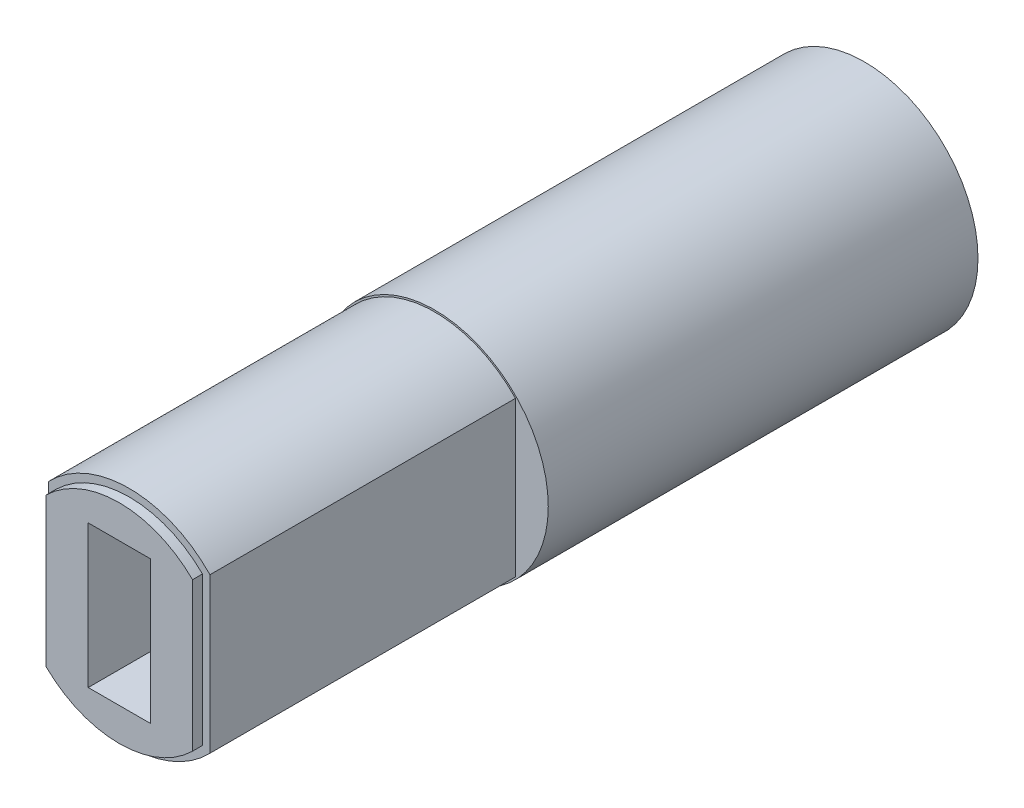
from build123d import *

# Parameters (mm, degrees)
SKETCH2_R           = 4.57
BOSS_EXTRUDE1_DEPTH = 17.3
BOSS_EXTRUDE3_DEPTH = 12.7
SKETCH5_W           = 2.5
SKETCH5_H           = 5.74
CUT_EXTRUDE1_DEPTH  = 31
SKETCH6_R           = 4.5
CUT_EXTRUDE3_DEPTH  = 0.4


with BuildPart() as part:
    # Sketch2 → Boss-Extrude1 (new body)
    with BuildSketch(Plane.XY):
        Circle(SKETCH2_R)
    extrude(amount=BOSS_EXTRUDE1_DEPTH)

    # Sketch4 → Boss-Extrude3 (add)
    with BuildSketch(Plane.XY.offset(17.3)):
        with BuildLine():
            Line((-3.25, 3.112474899), (-3.25, -3.112474899))
            ThreePointArc((-3.25, -3.112474899), (0, -4.5), (3.25, -3.112474899))
            Line((3.25, -3.112474899), (3.25, 3.112474899))
            ThreePointArc((3.25, 3.112474899), (0, 4.5), (-3.25, 3.112474899))
        make_face()
    extrude(amount=BOSS_EXTRUDE3_DEPTH)

    # Sketch5 → Cut-Extrude1 (cut, through all)
    with BuildSketch(Plane.XY.offset(30)):
        Rectangle(SKETCH5_W, SKETCH5_H)
    extrude(amount=-CUT_EXTRUDE1_DEPTH, mode=Mode.SUBTRACT)

    # Sketch6 → Cut-Extrude3 (cut)
    with BuildSketch(Plane.XY.offset(30)):
        Circle(SKETCH6_R)
        with BuildLine():
            Line((-2.95, 2.989565186), (-2.95, -2.989565186))
            ThreePointArc((-2.95, -2.989565186), (0, -4.2), (2.95, -2.989565186))
            Line((2.95, -2.989565186), (2.95, 2.989565186))
            ThreePointArc((2.95, 2.989565186), (0, 4.2), (-2.95, 2.989565186))
        make_face(mode=Mode.SUBTRACT)
    extrude(amount=-CUT_EXTRUDE3_DEPTH, mode=Mode.SUBTRACT)


solid = part.part
